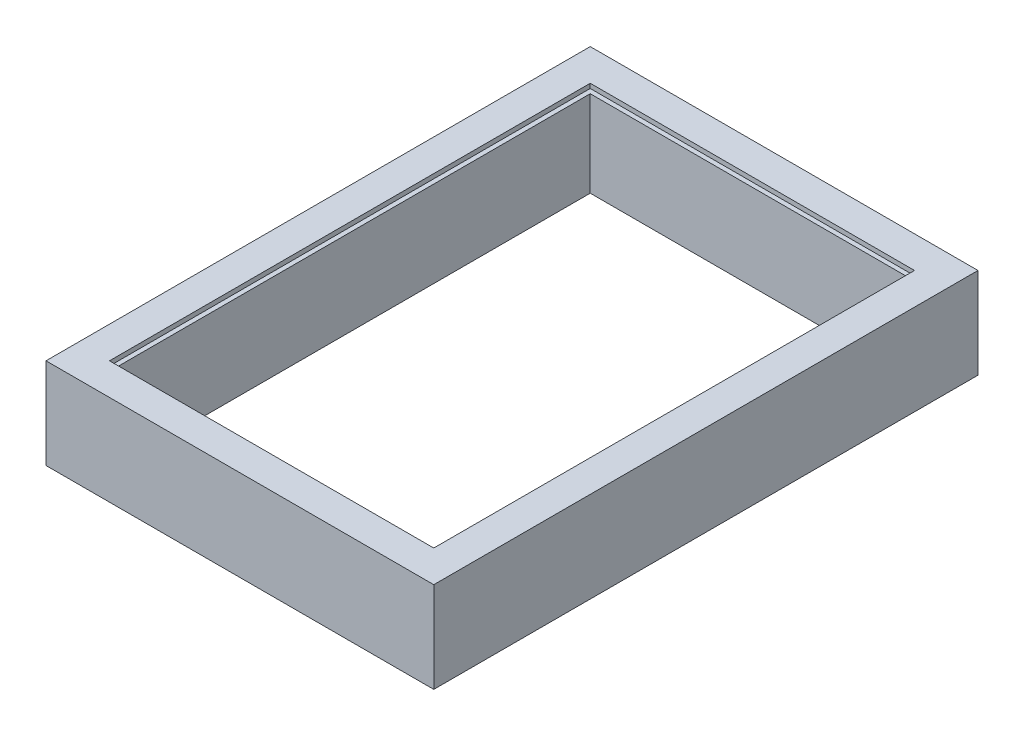
from build123d import *

# Parameters (mm, degrees)
SKETCH_1_W          = 855
SKETCH_1_H          = 1200
SKETCH_1_W_2        = 695
SKETCH_1_H_2        = 1040
EXTRUDE_1_DEPTH     = 200
SKETCH_2_W          = 715
SKETCH_2_H          = 1060
CUT_EXTRUDE_1_DEPTH = 10


with BuildPart() as part:
    # Эскиз1 → Вытянуть-Тонкостенный1 (new body)
    with BuildSketch(Plane(origin=(0, 0, 0), x_dir=(1, 0, 0), z_dir=(0, 1, 0))):
        Rectangle(SKETCH_1_W, SKETCH_1_H)
        Rectangle(SKETCH_1_W_2, SKETCH_1_H_2, mode=Mode.SUBTRACT)
    extrude(amount=EXTRUDE_1_DEPTH)

    # Эскиз2 → Вырез-Вытянуть1 (cut)
    with BuildSketch(Plane(origin=(0, 200, 0), x_dir=(1, 0, 0), z_dir=(0, 1, 0))):
        Rectangle(SKETCH_2_W, SKETCH_2_H)
    extrude(amount=-CUT_EXTRUDE_1_DEPTH, mode=Mode.SUBTRACT)


solid = part.part
